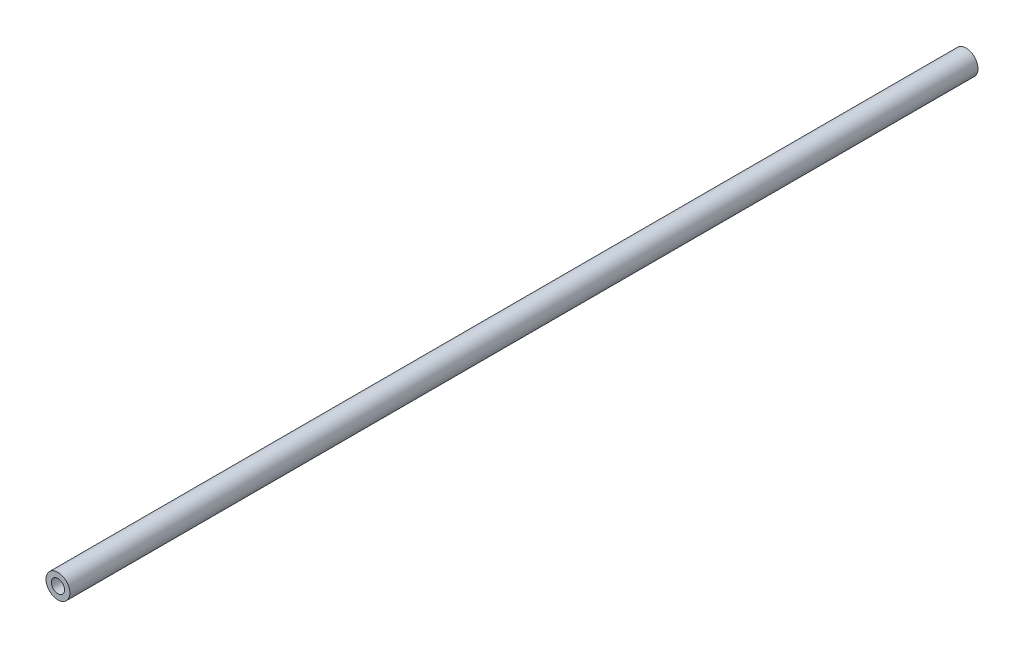
from build123d import *

# Parameters (mm, degrees)
SKETCH1_R                       = 3.175
BOSS_EXTRUDE1_DEPTH             = 241.3
F_6_32_TAPPED_HOLE1_D           = 2.7051
F_6_32_TAPPED_HOLE1_DEPTH       = 9.398
F_6_32_TAPPED_HOLE1_CBORE_D     = 3.5052
F_6_32_TAPPED_HOLE1_CBORE_DEPTH = 7.112
F_6_32_TAPPED_HOLE1_TIP         = 0.81269403
F_6_32_TAPPED_HOLE2_D           = 2.7051
F_6_32_TAPPED_HOLE2_DEPTH       = 9.398
F_6_32_TAPPED_HOLE2_CBORE_D     = 3.5052
F_6_32_TAPPED_HOLE2_CBORE_DEPTH = 7.112
F_6_32_TAPPED_HOLE2_TIP         = 0.81269403


with BuildPart() as part:
    # Sketch1 → Boss-Extrude1 (new body)
    with BuildSketch(Plane.XY):
        Circle(SKETCH1_R)
    extrude(amount=BOSS_EXTRUDE1_DEPTH)

    # #6-32 Tapped Hole1
    with Locations(Plane.XY.offset(241.3)):
        with Locations((0, 0)):
            CounterBoreHole(F_6_32_TAPPED_HOLE1_D / 2, F_6_32_TAPPED_HOLE1_CBORE_D / 2, F_6_32_TAPPED_HOLE1_CBORE_DEPTH, depth=F_6_32_TAPPED_HOLE1_DEPTH)
            with Locations((0, 0, -(F_6_32_TAPPED_HOLE1_DEPTH + F_6_32_TAPPED_HOLE1_TIP / 2))):  # 118° drill point
                Cone(0, F_6_32_TAPPED_HOLE1_D / 2, F_6_32_TAPPED_HOLE1_TIP, mode=Mode.SUBTRACT)

    # #6-32 Tapped Hole2
    with Locations(Plane(origin=(0, 0, 0), x_dir=(-1, 0, 0), z_dir=(0, 0, -1))):
        with Locations((0, 0)):
            CounterBoreHole(F_6_32_TAPPED_HOLE2_D / 2, F_6_32_TAPPED_HOLE2_CBORE_D / 2, F_6_32_TAPPED_HOLE2_CBORE_DEPTH, depth=F_6_32_TAPPED_HOLE2_DEPTH)
            with Locations((0, 0, -(F_6_32_TAPPED_HOLE2_DEPTH + F_6_32_TAPPED_HOLE2_TIP / 2))):  # 118° drill point
                Cone(0, F_6_32_TAPPED_HOLE2_D / 2, F_6_32_TAPPED_HOLE2_TIP, mode=Mode.SUBTRACT)


solid = part.part
